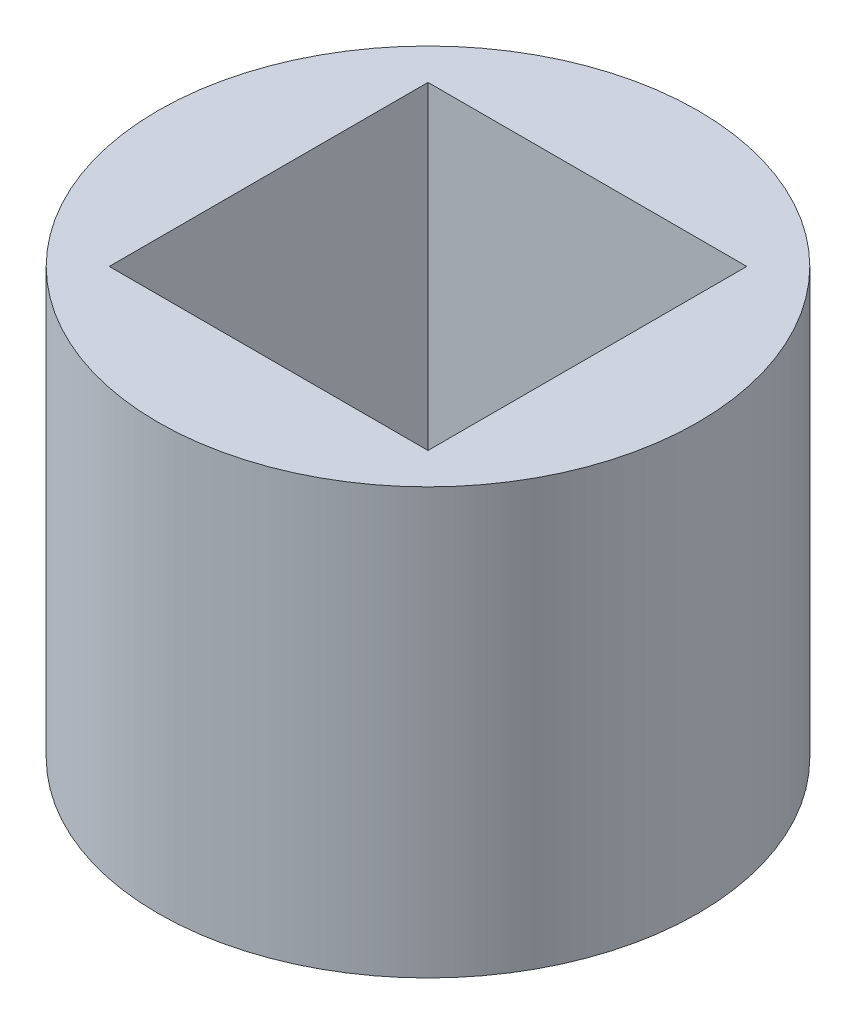
from build123d import *

# Parameters (mm, degrees)
SKETCH1_R           = 12.695
SKETCH1_W           = 14.99
SKETCH1_H           = 14.99
BOSS_EXTRUDE2_DEPTH = 20


with BuildPart() as part:
    # Sketch1 → Boss-Extrude2 (new body)
    with BuildSketch(Plane(origin=(0, 0, 0), x_dir=(1, 0, 0), z_dir=(0, 1, 0))):
        Circle(SKETCH1_R)
        Rectangle(SKETCH1_W, SKETCH1_H, mode=Mode.SUBTRACT)
    extrude(amount=BOSS_EXTRUDE2_DEPTH)


solid = part.part
